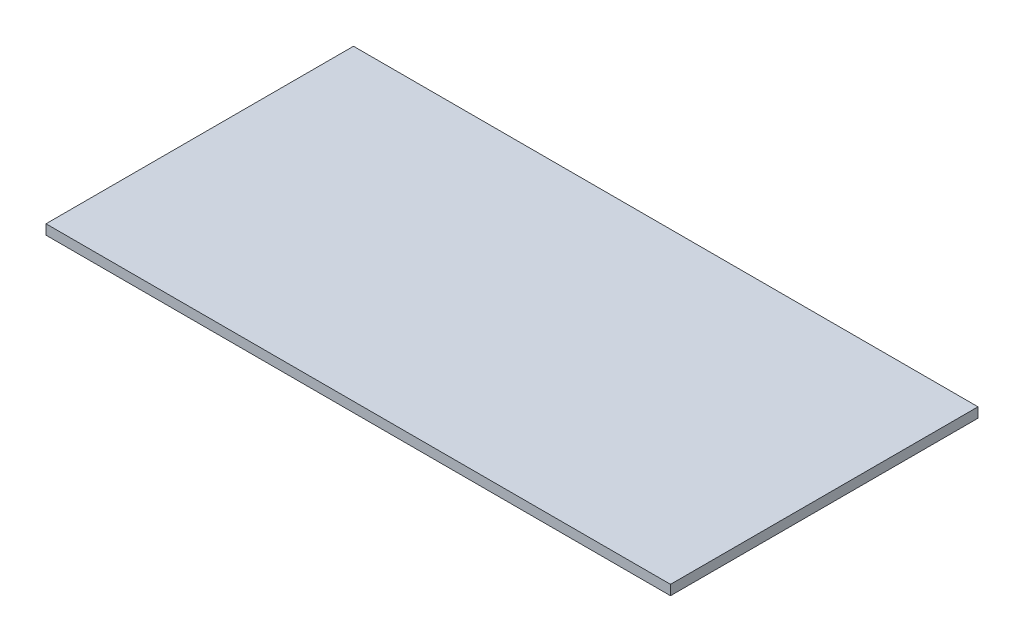
from build123d import *

# Parameters (mm, degrees)
SKETCH1_W           = 126
SKETCH1_H           = 62.04
BOSS_EXTRUDE1_DEPTH = 2


with BuildPart() as part:
    # Sketch1 → Boss-Extrude1 (new body)
    with BuildSketch(Plane(origin=(0, 0, 0), x_dir=(1, 0, 0), z_dir=(0, 1, 0))):
        Rectangle(SKETCH1_W, SKETCH1_H)
    extrude(amount=BOSS_EXTRUDE1_DEPTH)


solid = part.part
